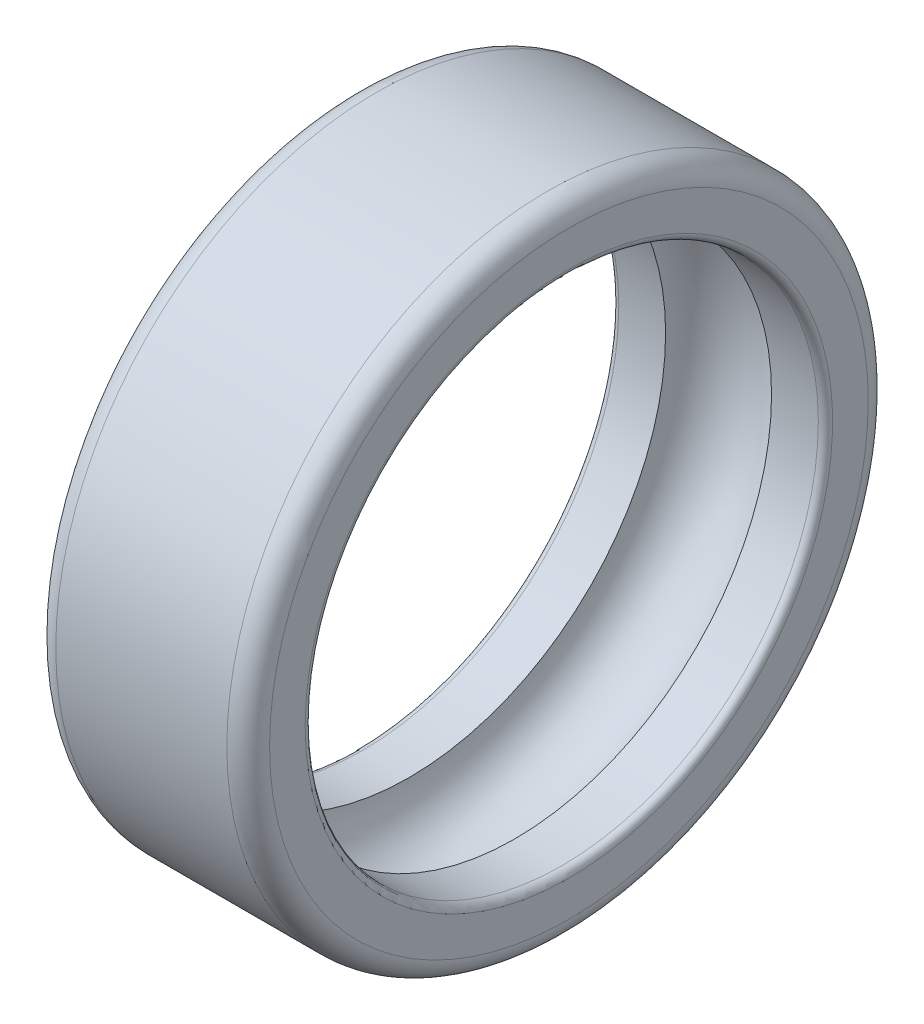
from build123d import *


with BuildPart() as part:
    # Sketch1 → Revolve1 (revolve)
    with BuildSketch(Plane(origin=(0, 0, 0), x_dir=(-1, 0, 0), z_dir=(0, 0, -1))):
        with BuildLine():
            Line((-6.9, 16.65), (-6.243303437, 16.65))
            ThreePointArc((-6.243303437, 16.65), (-5.5, 17.3), (-4.756696563, 16.65))
            Line((-4.756696563, 16.65), (-4.1, 16.65))
            ThreePointArc((-4.1, 16.65), (-4.029289322, 16.679289322), (-4, 16.75))
            Line((-4, 16.75), (-4, 17.25))
            ThreePointArc((-4, 17.25), (-4.087867966, 17.462132034), (-4.3, 17.55))
            Line((-4.3, 17.55), (-6.7, 17.55))
            ThreePointArc((-6.7, 17.55), (-6.912132034, 17.462132034), (-7, 17.25))
            Line((-7, 17.25), (-7, 16.75))
            ThreePointArc((-7, 16.75), (-6.970710678, 16.679289322), (-6.9, 16.65))
        make_face()
    revolve(axis=Axis((8.051399781, 13.05, 0), (-1, 0, 0)))


solid = part.part
